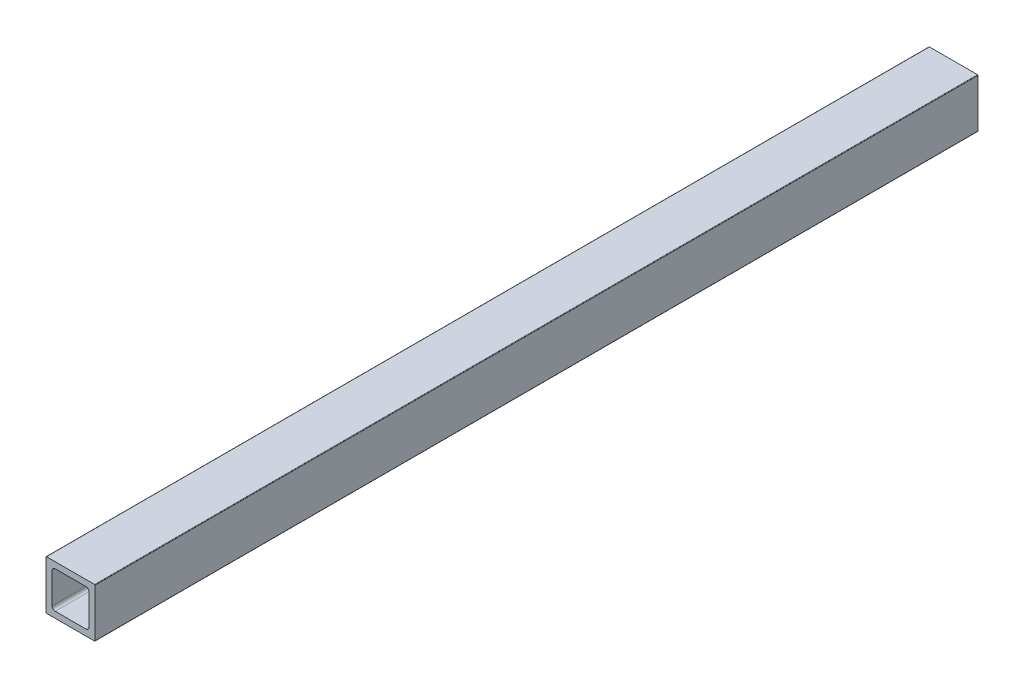
from build123d import *

# Parameters (mm, degrees)
BOSS_EXTRUDE1_DEPTH = 457.2


with BuildPart() as part:
    # Sketch1 → Boss-Extrude1 (new body)
    with BuildSketch(Plane(origin=(0, 0, 0), x_dir=(-1, 0, 0), z_dir=(0, 0, -1))):
        with BuildLine():
            Line((0, 0.254), (0, 25.146))
            ThreePointArc((0, 25.146), (-0.074394878, 25.325605122), (-0.254, 25.4))
            Line((-0.254, 25.4), (-25.146, 25.4))
            ThreePointArc((-25.146, 25.4), (-25.325605122, 25.325605122), (-25.4, 25.146))
            Line((-25.4, 25.146), (-25.4, 0.254))
            ThreePointArc((-25.4, 0.254), (-25.325605122, 0.074394878), (-25.146, 0))
            Line((-25.146, 0), (-0.254, 0))
            ThreePointArc((-0.254, 0), (-0.074394878, 0.074394878), (0, 0.254))
        make_face()
        with BuildLine():
            Line((-3.175, 20.6375), (-3.175, 4.7625))
            ThreePointArc((-3.175, 4.7625), (-3.639967985, 3.639967985), (-4.7625, 3.175))
            Line((-4.7625, 3.175), (-20.6375, 3.175))
            ThreePointArc((-20.6375, 3.175), (-21.760032015, 3.639967985), (-22.225, 4.7625))
            Line((-22.225, 4.7625), (-22.225, 20.6375))
            ThreePointArc((-22.225, 20.6375), (-21.760032015, 21.760032015), (-20.6375, 22.225))
            Line((-20.6375, 22.225), (-4.7625, 22.225))
            ThreePointArc((-4.7625, 22.225), (-3.639967985, 21.760032015), (-3.175, 20.6375))
        make_face(mode=Mode.SUBTRACT)
    extrude(amount=-BOSS_EXTRUDE1_DEPTH)


solid = part.part
